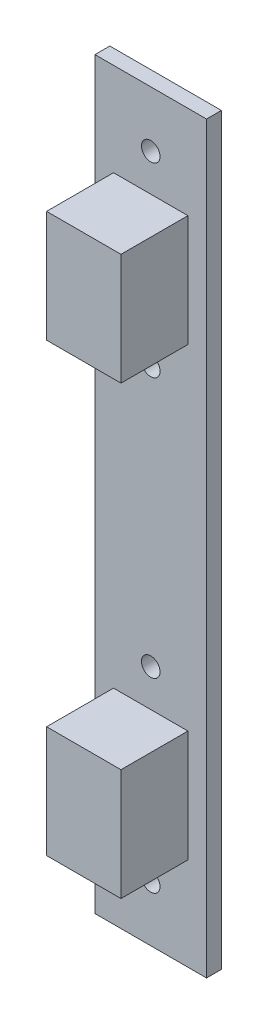
from build123d import *

# Parameters (mm, degrees)
CROQUIS1_W              = 15
CROQUIS1_H              = 100
CROQUIS1_R              = 1.25
SALIENTE_EXTRUIR1_DEPTH = 2
CROQUIS2_W              = 10
CROQUIS2_H              = 15
SALIENTE_EXTRUIR2_DEPTH = 9


with BuildPart() as part:
    # Croquis1 → Saliente-Extruir1 (new body)
    with BuildSketch(Plane.XY):
        Rectangle(CROQUIS1_W, CROQUIS1_H)
        with Locations((0, 42.5)):
            Circle(CROQUIS1_R, mode=Mode.SUBTRACT)
        with Locations((0, 17.5)):
            Circle(CROQUIS1_R, mode=Mode.SUBTRACT)
        with Locations((0, -42.5)):
            Circle(CROQUIS1_R, mode=Mode.SUBTRACT)
        with Locations((0, -17.5)):
            Circle(CROQUIS1_R, mode=Mode.SUBTRACT)
    extrude(amount=-SALIENTE_EXTRUIR1_DEPTH)

    # Croquis2 → Saliente-Extruir2 (add)
    with BuildSketch(Plane.XY):
        with Locations((0, 30)):
            Rectangle(CROQUIS2_W, CROQUIS2_H)
        with Locations((0, -30)):
            Rectangle(CROQUIS2_W, CROQUIS2_H)
    extrude(amount=SALIENTE_EXTRUIR2_DEPTH)


solid = part.part
